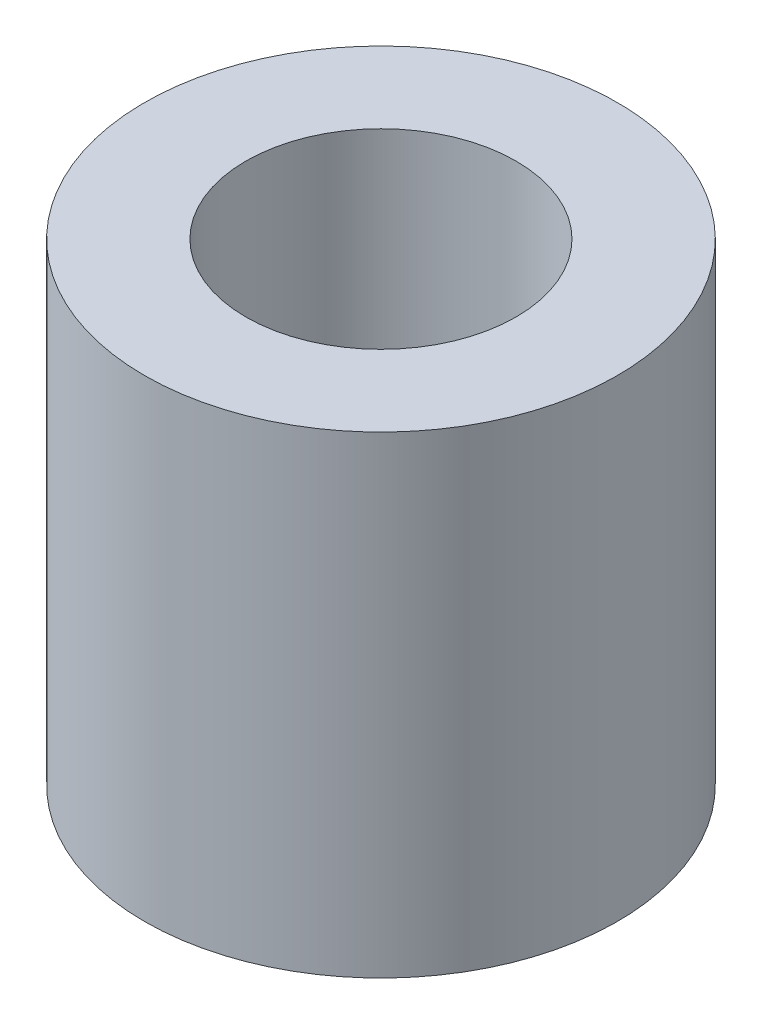
from build123d import *

# Parameters (mm, degrees)
SKETCH1_R           = 3.5
SKETCH1_R_2         = 2
BOSS_EXTRUDE1_DEPTH = 3.5


with BuildPart() as part:
    # Sketch1 → Boss-Extrude1 (new body, symmetric)
    with BuildSketch(Plane(origin=(0, 0, 0), x_dir=(1, 0, 0), z_dir=(0, 1, 0))):
        Circle(SKETCH1_R)
        Circle(SKETCH1_R_2, mode=Mode.SUBTRACT)
    extrude(amount=BOSS_EXTRUDE1_DEPTH, both=True)


solid = part.part
